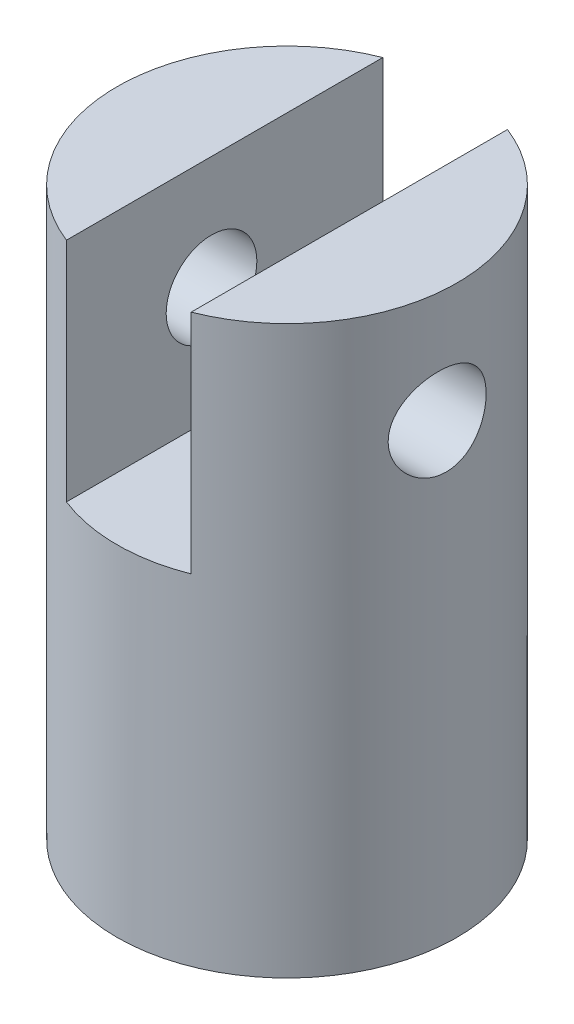
from build123d import *

# Parameters (mm, degrees)
SKETCH1_R                      = 7.5
BOSS_EXTRUDE1_DEPTH            = 25
SKETCH2_W                      = 5.5
SKETCH2_H                      = 15
CUT_EXTRUDE1_DEPTH             = 10
CUT_EXTRUDE2_REACH             = 9.5
SKETCH3_R                      = 2
CUT_EXTRUDE2_DIRECTION_2_REACH = 9.5


with BuildPart() as part:
    # Sketch1 → Boss-Extrude1 (new body)
    with BuildSketch(Plane(origin=(0, 0, 0), x_dir=(1, 0, 0), z_dir=(0, 1, 0))):
        Circle(SKETCH1_R)
    extrude(amount=BOSS_EXTRUDE1_DEPTH)

    # Sketch2 → Cut-Extrude1 (cut)
    with BuildSketch(Plane(origin=(0, 25, 0), x_dir=(1, 0, 0), z_dir=(0, 1, 0))):
        Rectangle(SKETCH2_W, SKETCH2_H)
    extrude(amount=-CUT_EXTRUDE1_DEPTH, mode=Mode.SUBTRACT)

    # Sketch3 → Cut-Extrude2 (cut, up to next)
    with BuildSketch(Plane(origin=(0, 0, 0), x_dir=(0, 0, -1), z_dir=(1, 0, 0)), mode=Mode.PRIVATE) as cut_extrude2_sk1:
        with Locations((-0.579819459, 20)):
            Circle(SKETCH3_R)
    cut_extrude2_tool1 = extrude(cut_extrude2_sk1.sketch, amount=-CUT_EXTRUDE2_REACH, mode=Mode.PRIVATE) & part.part
    add(cut_extrude2_tool1.solids().sort_by_distance((0, 20, 0.579819))[0], mode=Mode.SUBTRACT)

    # Sketch3 → Cut-Extrude2 direction 2 (cut, up to next)
    with BuildSketch(Plane(origin=(0, 0, 0), x_dir=(0, 0, -1), z_dir=(1, 0, 0)), mode=Mode.PRIVATE) as cut_extrude2_direction_2_sk1:
        with Locations((-0.579819459, 20)):
            Circle(SKETCH3_R)
    cut_extrude2_direction_2_tool1 = extrude(cut_extrude2_direction_2_sk1.sketch, amount=CUT_EXTRUDE2_DIRECTION_2_REACH, mode=Mode.PRIVATE) & part.part
    add(cut_extrude2_direction_2_tool1.solids().sort_by_distance((0, 20, 0.579819))[0], mode=Mode.SUBTRACT)


solid = part.part
